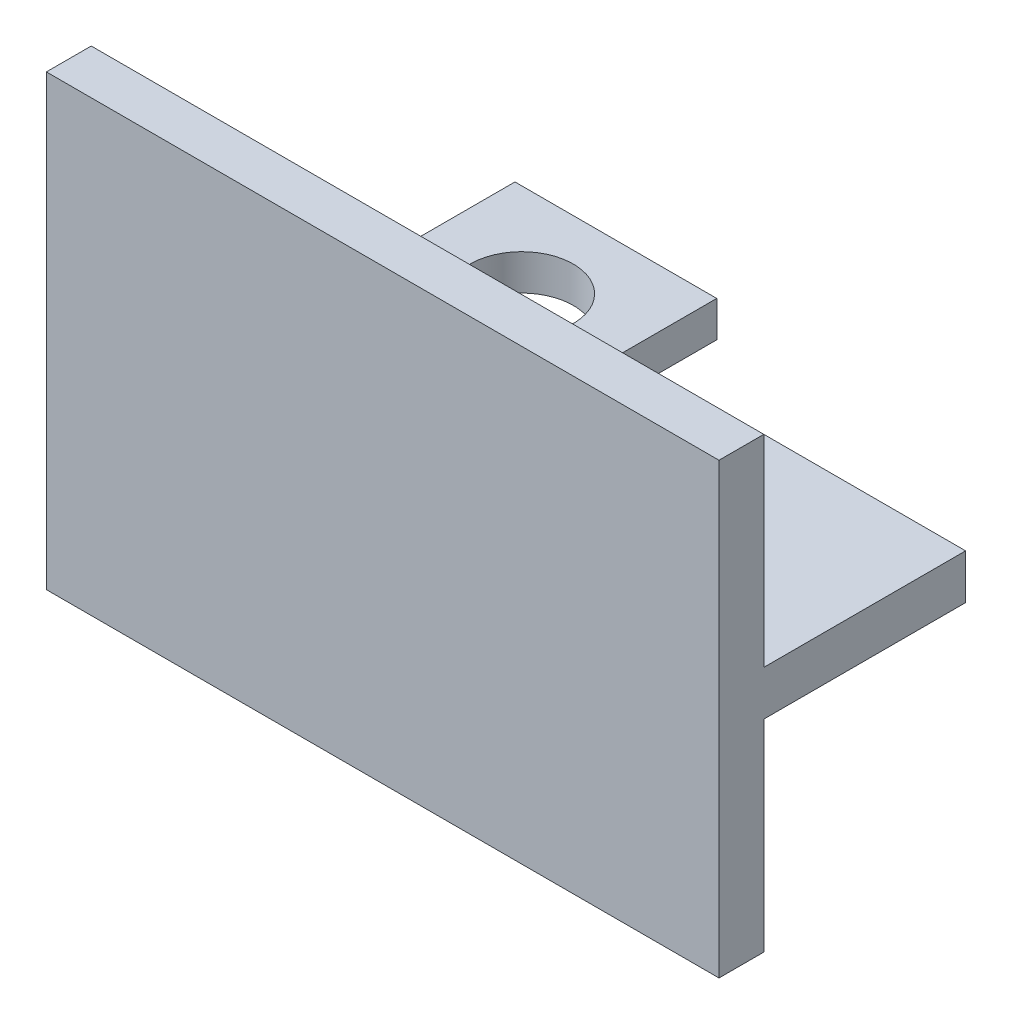
from build123d import *

# Parameters (mm, degrees)
SKETCH1_W                = 150
SKETCH1_H                = 10
BOSS_EXTRUDE1_DEPTH      = 55
SKETCH2_W                = 150
SKETCH2_H                = 10
BOSS_EXTRUDE2_DEPTH      = 45
BOSS_EXTRUDE2_DEPTH_BACK = 55
SKETCH3_W                = 45
SKETCH3_H                = 8
BOSS_EXTRUDE3_DEPTH      = 42
SKETCH4_W                = 56.520568853
SKETCH4_H                = 45
CUT_EXTRUDE1_DEPTH       = 56
SKETCH5_R                = 11.5
CUT_EXTRUDE2_DEPTH       = 80


with BuildPart() as part:
    # Sketch1 → Boss-Extrude1 (new body)
    with BuildSketch(Plane.XY):
        with Locations((112.750906932, 878.250348045)):
            Rectangle(SKETCH1_W, SKETCH1_H)
    extrude(amount=-BOSS_EXTRUDE1_DEPTH)

    # Sketch2 → Boss-Extrude2 (add, two sides)
    with BuildSketch(Plane(origin=(0, 883.250348045, 0), x_dir=(1, 0, 0), z_dir=(0, 1, 0))) as boss_extrude2_sk:
        with Locations((112.750906932, 5)):
            Rectangle(SKETCH2_W, SKETCH2_H)
    extrude(amount=BOSS_EXTRUDE2_DEPTH)
    extrude(boss_extrude2_sk.sketch, amount=-BOSS_EXTRUDE2_DEPTH_BACK)

    # Sketch3 → Boss-Extrude3 (add)
    with BuildSketch(Plane(origin=(0, 0, -10), x_dir=(-1, 0, 0), z_dir=(0, 0, -1))):
        with Locations((-112.750906932, 903.250348045)):
            Rectangle(SKETCH3_W, SKETCH3_H)
    extrude(amount=BOSS_EXTRUDE3_DEPTH)

    # Sketch4 → Cut-Extrude1 (cut, through all)
    with BuildSketch(Plane(origin=(0, 883.250348045, 0), x_dir=(1, 0, 0), z_dir=(0, 1, 0))):
        with Locations((113.076467001, 32.5)):
            Rectangle(SKETCH4_W, SKETCH4_H)
    extrude(amount=-CUT_EXTRUDE1_DEPTH, mode=Mode.SUBTRACT)

    # Sketch5 → Cut-Extrude2 (cut, through all)
    with BuildSketch(Plane(origin=(0, 907.250348045, 0), x_dir=(1, 0, 0), z_dir=(0, 1, 0))):
        with Locations((112.600906932, 31.15)):
            Circle(SKETCH5_R)
    extrude(amount=-CUT_EXTRUDE2_DEPTH, mode=Mode.SUBTRACT)


solid = part.part
